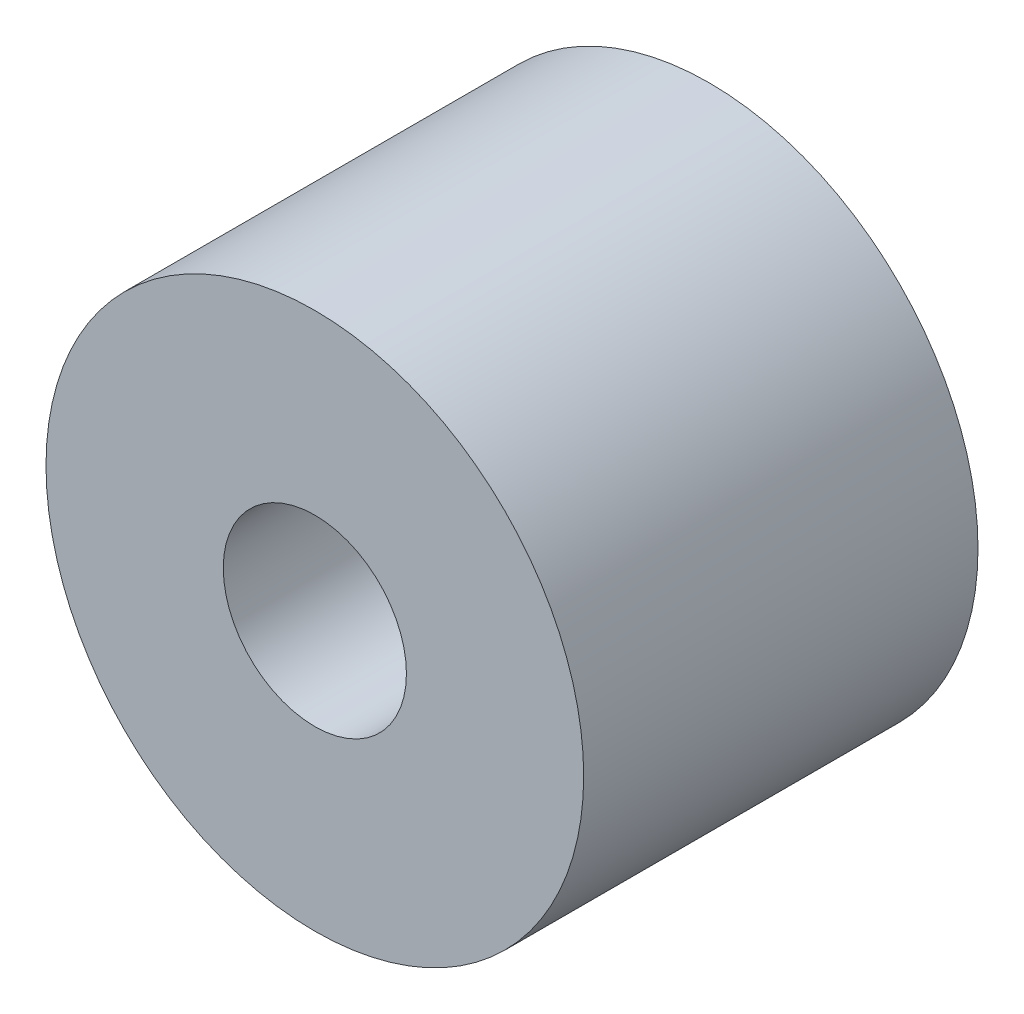
from build123d import *

# Parameters (mm, degrees)
SKETCH1_R           = 7.5
SKETCH1_R_2         = 2.555
BOSS_EXTRUDE1_DEPTH = 11


with BuildPart() as part:
    # Sketch1 → Boss-Extrude1 (new body)
    with BuildSketch(Plane.XY):
        Circle(SKETCH1_R)
        Circle(SKETCH1_R_2, mode=Mode.SUBTRACT)
    extrude(amount=BOSS_EXTRUDE1_DEPTH)


solid = part.part
